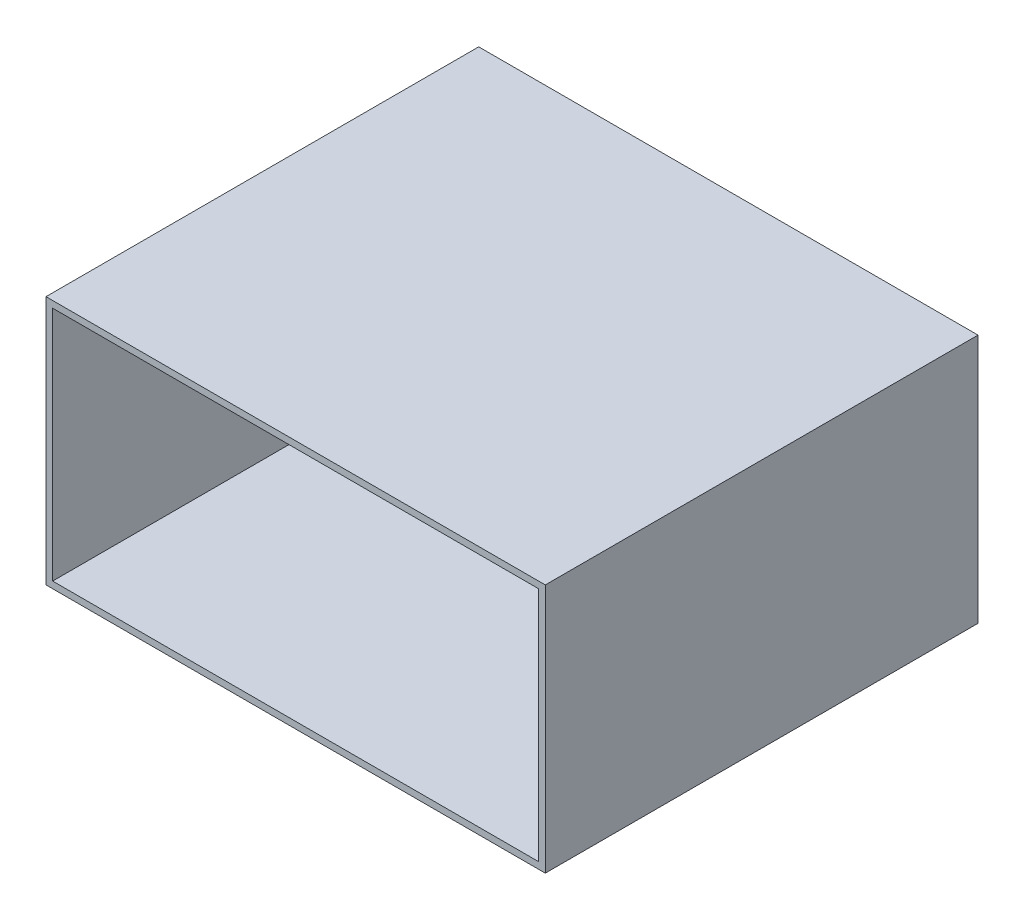
from build123d import *

# Parameters (mm, degrees)
SKETCH1_W           = 750
SKETCH1_H           = 375
SKETCH1_W_2         = 730
SKETCH1_H_2         = 355
BOSS_EXTRUDE2_DEPTH = 650


with BuildPart() as part:
    # Sketch1 → Boss-Extrude2 (new body)
    with BuildSketch(Plane.XY):
        Rectangle(SKETCH1_W, SKETCH1_H)
        Rectangle(SKETCH1_W_2, SKETCH1_H_2, mode=Mode.SUBTRACT)
    extrude(amount=BOSS_EXTRUDE2_DEPTH)


solid = part.part
